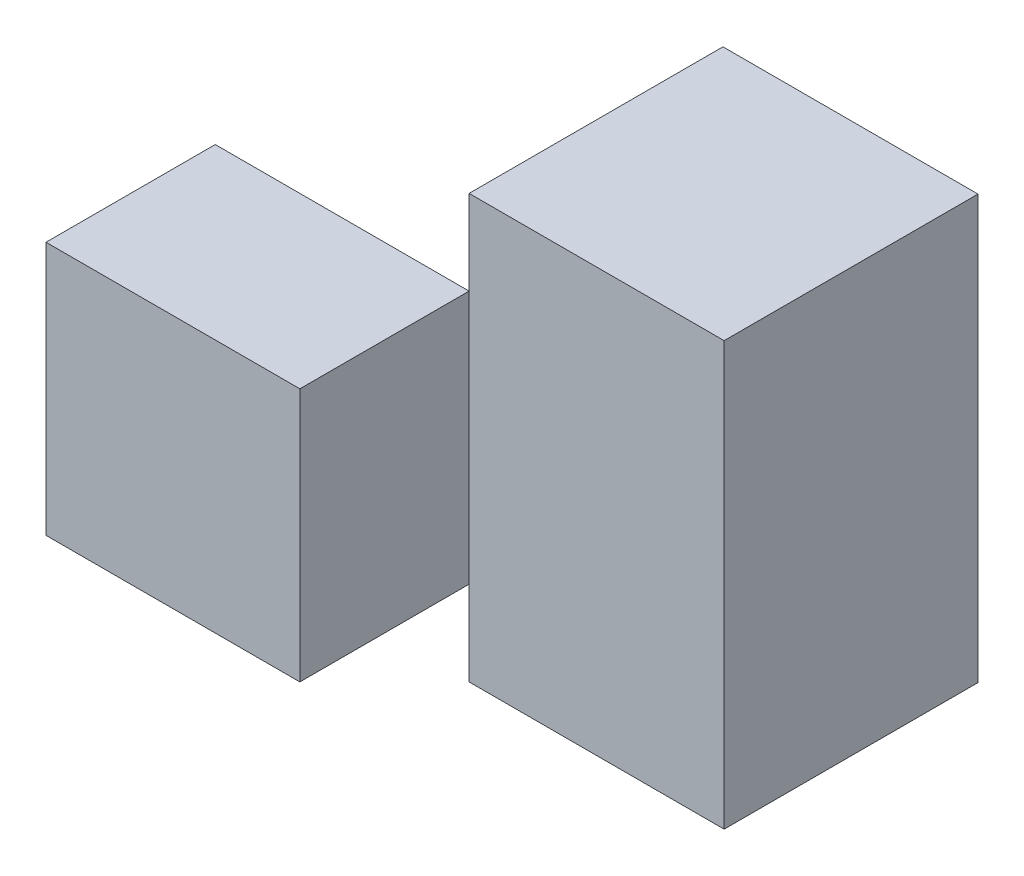
from build123d import *

# Parameters (mm, degrees)
SKETCH1_W            = 60
SKETCH1_H            = 50
BOSS_EXTRUDE1_DEPTH  = 50
SKETCH2_W            = 30
SKETCH2_H            = 10
CUT_EXTRUDE1_DEPTH   = 50
SKETCH3_W            = 20
SKETCH3_H            = 10
CUT_EXTRUDE2_DEPTH   = 50
SKETCH4_W            = 30
SKETCH4_H            = 30
SKETCH4_H_2          = 20
CUT_EXTRUDE3_DEPTH   = 50
CUT_EXTRUDE7_DEPTH   = 30
CUT_EXTRUDE8_DEPTH   = 30
SKETCH12_W           = 29.999
SKETCH12_H           = 30
CUT_EXTRUDE10_DEPTH  = 0.0001
SKETCH14_W           = 30
SKETCH14_H           = 50
BOSS_EXTRUDE15_DEPTH = 0.14


with BuildPart() as part:
    # Sketch1 → Boss-Extrude1 (new body)
    with BuildSketch(Plane.XY):
        Rectangle(SKETCH1_W, SKETCH1_H)
    extrude(amount=BOSS_EXTRUDE1_DEPTH)

    # Sketch2 → Cut-Extrude1 (cut)
    with BuildSketch(Plane.XY.offset(50)):
        with Locations((-15, 20)):
            Rectangle(SKETCH2_W, SKETCH2_H)
        with Locations((-15, -20)):
            Rectangle(SKETCH2_W, SKETCH2_H)
    extrude(amount=-CUT_EXTRUDE1_DEPTH, mode=Mode.SUBTRACT)

    # Sketch3 → Cut-Extrude2 (cut)
    with BuildSketch(Plane.ZY):
        with Locations((40, 20)):
            Rectangle(SKETCH3_W, SKETCH3_H)
        with Locations((40, -20)):
            Rectangle(SKETCH3_W, SKETCH3_H)
    extrude(amount=-CUT_EXTRUDE2_DEPTH, mode=Mode.SUBTRACT)

    # Sketch4 → Cut-Extrude3 (cut)
    with BuildSketch(Plane(origin=(0, 15, 0), x_dir=(1, 0, 0), z_dir=(0, 1, 0))):
        with Locations((-15, -15)):
            Rectangle(SKETCH4_W, SKETCH4_H)
        with Locations((15, -40)):
            Rectangle(SKETCH4_W, SKETCH4_H_2)
    extrude(amount=-CUT_EXTRUDE3_DEPTH, mode=Mode.SUBTRACT)

    # Sketch9 → Cut-Extrude7 (cut)
    with BuildSketch(Plane(origin=(0, -15, 0), x_dir=(1, 0, 0), z_dir=(0, 1, 0))):
        Polygon((0, 0), (29.999, -9.999), (0, -9.999), align=None)
    extrude(amount=CUT_EXTRUDE7_DEPTH, mode=Mode.SUBTRACT)

    # Sketch10 → Cut-Extrude8 (cut)
    with BuildSketch(Plane(origin=(0, -15, 0), x_dir=(1, 0, 0), z_dir=(0, 1, 0))):
        Polygon((0, -9.9991), (0, -29.9981), (29.999, -9.9991), align=None)
    extrude(amount=CUT_EXTRUDE8_DEPTH, mode=Mode.SUBTRACT)

    # Sketch12 → Cut-Extrude10 (cut)
    with BuildSketch(Plane(origin=(0, 0, 9.999), x_dir=(-1, 0, 0), z_dir=(0, 0, -1))):
        with Locations((-14.9995, 0)):
            Rectangle(SKETCH12_W, SKETCH12_H)
    extrude(amount=-CUT_EXTRUDE10_DEPTH, mode=Mode.SUBTRACT)

    # Sketch14 → Boss-Extrude15 (add)
    with BuildSketch(Plane(origin=(30, 0, 0), x_dir=(0, 0, -1), z_dir=(1, 0, 0))):
        with Locations((-15, 0)):
            Rectangle(SKETCH14_W, SKETCH14_H)
    extrude(amount=BOSS_EXTRUDE15_DEPTH)


solid = part.part
